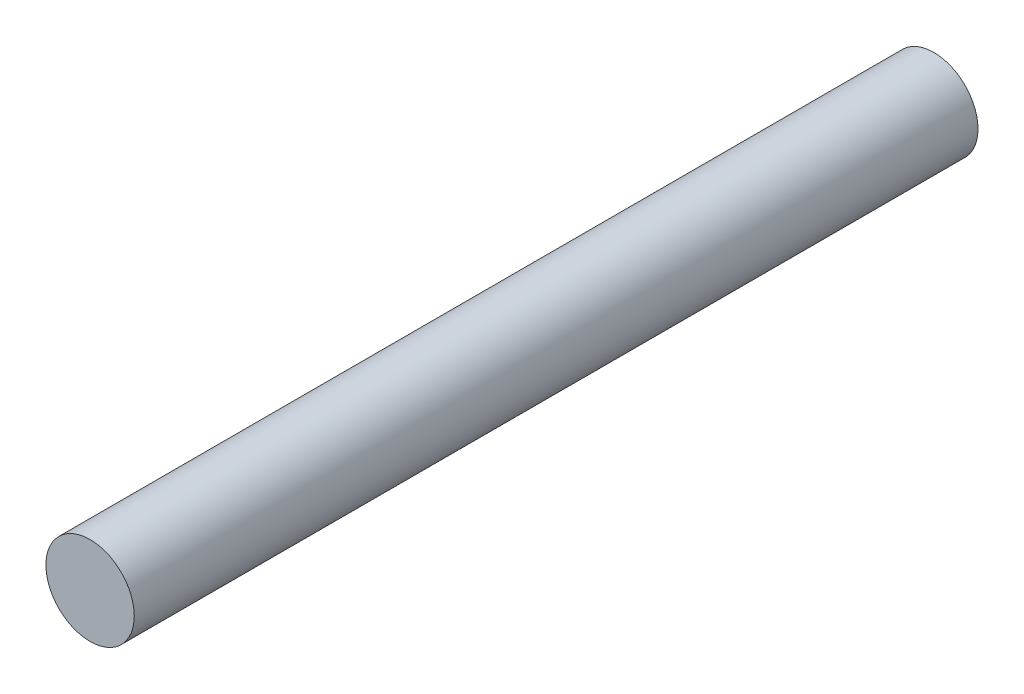
from build123d import *

# Parameters (mm, degrees)
SKETCH9_R      = 1.27
EXTRUDE2_DEPTH = 24.257


with BuildPart() as part:
    # Sketch9 → Extrude2 (new body)
    with BuildSketch(Plane.XY):
        Circle(SKETCH9_R)
    extrude(amount=EXTRUDE2_DEPTH)


solid = part.part
